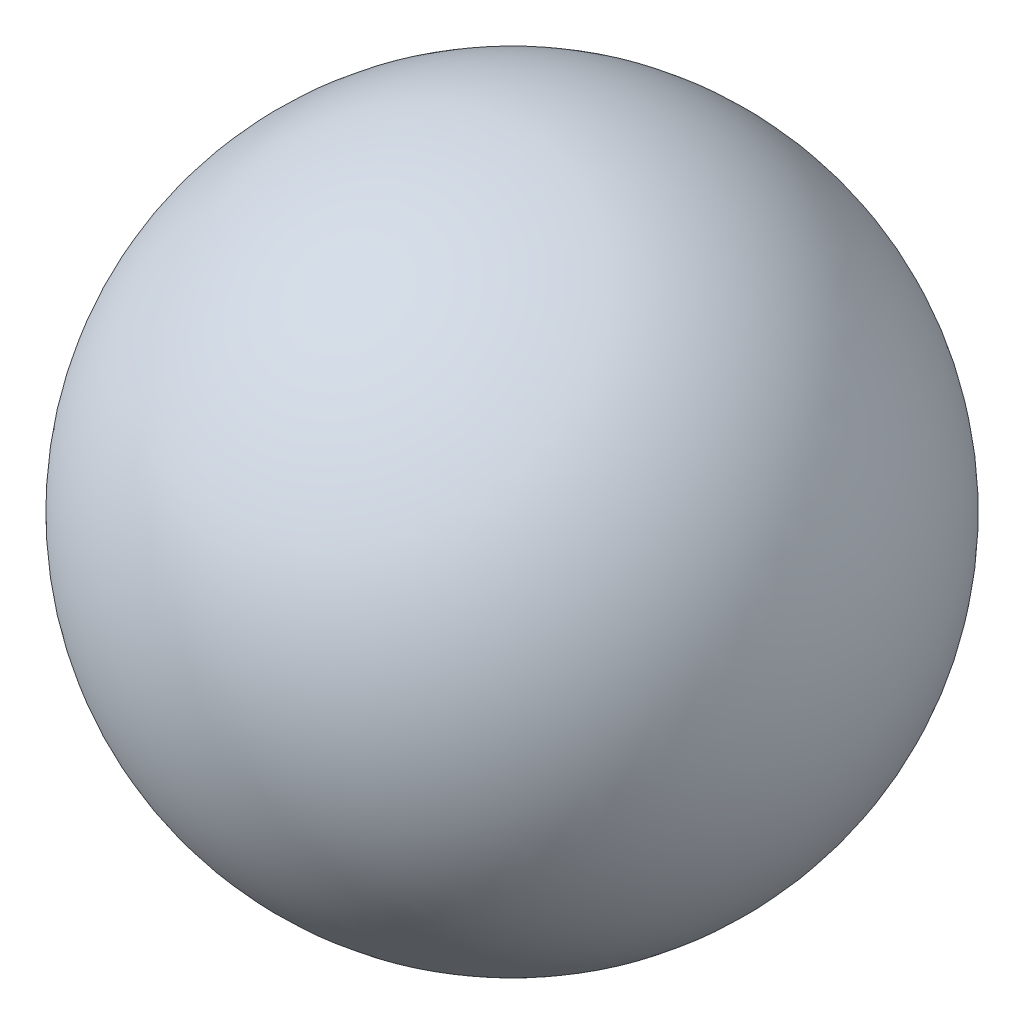
from build123d import *

# Parameters (mm, degrees)
AUFSATZ_LINEAR_AUSTRAGEN1_DEPTH = 2.5


with BuildPart() as part:
    # Skizze1 → Aufsatz-Linear austragen1 (new body, symmetric)
    with BuildSketch(Plane.XY):
        with BuildLine():
            Line((-5, 0), (-5, 5))
            Line((-5, 5), (-2.5, 5))
            Line((-2.5, 5), (-2.5, 0))
            ThreePointArc((-2.5, 0), (0, -2.5), (2.5, 0))
            Line((2.5, 0), (2.5, 5))
            Line((2.5, 5), (5, 5))
            Line((5, 5), (5, -5))
            Line((5, -5), (2.5, -5))
            Line((2.5, -5), (2.5, -4.330127019))
            ThreePointArc((2.5, -4.330127019), (-2.5, -4.330127019), (-5, 0))
        make_face()
    extrude(amount=AUFSATZ_LINEAR_AUSTRAGEN1_DEPTH, both=True)


with BuildPart() as body_2:
    # Skizze2 → Rotation1 (revolve)
    with BuildSketch(Plane.XY):
        with BuildLine():
            Line((0, 10), (0, -10))
            ThreePointArc((0, -10), (-10, 0), (0, 10))
        make_face()
    revolve(axis=Axis((0, 10, 0), (0, -1, 0)))


solid = Compound([part.part, body_2.part])
